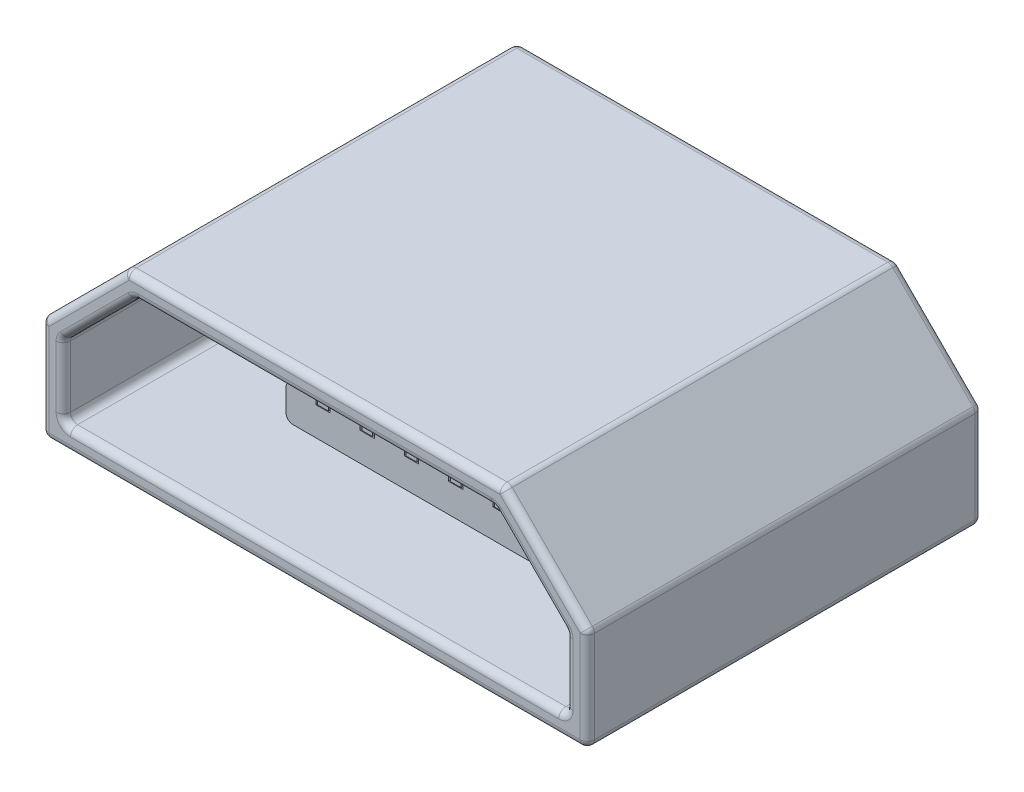
from build123d import *

# Parameters (mm, degrees)
EXTRUDE_THIN1_DEPTH = 5.5
BOSS_EXTRUDE1_DEPTH = 2.5
SKETCH3_W           = 3.5
SKETCH3_H           = 0.5
BOSS_EXTRUDE2_DEPTH = 1.65
SKETCH4_W           = 0.2
SKETCH4_H           = 0.1
CUT_EXTRUDE1_DEPTH  = 1.65
BOSS_EXTRUDE4_REACH = 6.15
SKETCH5_W           = 0.15
SKETCH5_H           = 0.09
FILLET1_R           = 0.1


with BuildPart() as part:
    # Sketch1 → Extrude-Thin1 (new body)
    with BuildSketch(Plane.XY):
        Polygon((-0.3, -0.3), (7.3, -0.3), (7.3, 1.124264069), (6.124264069, 2.3), (0.875735931, 2.3), (-0.3, 1.124264069), align=None)
        Polygon((0, 0), (7, 0), (7, 1), (6, 2), (1, 2), (0, 1), align=None, mode=Mode.SUBTRACT)
    extrude(amount=EXTRUDE_THIN1_DEPTH)

    # Sketch2 → Boss-Extrude1 (add)
    with BuildSketch(Plane(origin=(0, 0, 0), x_dir=(-1, 0, 0), z_dir=(0, 0, -1))):
        Polygon((-6, 2), (-1, 2), (0, 1), (0, 0), (-7, 0), (-7, 1), align=None)
    extrude(amount=-BOSS_EXTRUDE1_DEPTH)

    # Sketch3 → Boss-Extrude2 (add)
    with BuildSketch(Plane.XY.offset(2.5)):
        with Locations((3.5, 0.5)):
            Rectangle(SKETCH3_W, SKETCH3_H)
    extrude(amount=BOSS_EXTRUDE2_DEPTH)

    # Sketch4 → Cut-Extrude1 (cut)
    with BuildSketch(Plane.XY.offset(4.15)):
        with Locations((2.266666667, 0.7)):
            Rectangle(SKETCH4_W, SKETCH4_H)
        with Locations((2.883333333, 0.7)):
            Rectangle(SKETCH4_W, SKETCH4_H)
        with Locations((3.5, 0.7)):
            Rectangle(SKETCH4_W, SKETCH4_H)
        with Locations((4.116666667, 0.7)):
            Rectangle(SKETCH4_W, SKETCH4_H)
        with Locations((4.733333333, 0.7)):
            Rectangle(SKETCH4_W, SKETCH4_H)
    extrude(amount=-CUT_EXTRUDE1_DEPTH, mode=Mode.SUBTRACT)

    # Sketch5 → Boss-Extrude4 (add, up to next)
    with BuildSketch(Plane.XY.offset(4.15), mode=Mode.PRIVATE) as boss_extrude4_sk1:
        with Locations((2.266666667, 0.705)):
            Rectangle(SKETCH5_W, SKETCH5_H)
    boss_extrude4_tool1 = extrude(boss_extrude4_sk1.sketch, amount=-BOSS_EXTRUDE4_REACH, mode=Mode.PRIVATE) - part.part
    add(boss_extrude4_tool1.solids().sort_by_distance((2.266667, 0.705, 4.15))[0])
    # Sketch5 → Boss-Extrude4 (add, up to next)
    with BuildSketch(Plane.XY.offset(4.15), mode=Mode.PRIVATE) as boss_extrude4_sk2:
        with Locations((2.883333333, 0.705)):
            Rectangle(SKETCH5_W, SKETCH5_H)
    boss_extrude4_tool2 = extrude(boss_extrude4_sk2.sketch, amount=-BOSS_EXTRUDE4_REACH, mode=Mode.PRIVATE) - part.part
    add(boss_extrude4_tool2.solids().sort_by_distance((2.883333, 0.705, 4.15))[0])
    # Sketch5 → Boss-Extrude4 (add, up to next)
    with BuildSketch(Plane.XY.offset(4.15), mode=Mode.PRIVATE) as boss_extrude4_sk3:
        with Locations((3.5, 0.705)):
            Rectangle(SKETCH5_W, SKETCH5_H)
    boss_extrude4_tool3 = extrude(boss_extrude4_sk3.sketch, amount=-BOSS_EXTRUDE4_REACH, mode=Mode.PRIVATE) - part.part
    add(boss_extrude4_tool3.solids().sort_by_distance((3.5, 0.705, 4.15))[0])
    # Sketch5 → Boss-Extrude4 (add, up to next)
    with BuildSketch(Plane.XY.offset(4.15), mode=Mode.PRIVATE) as boss_extrude4_sk4:
        with Locations((4.116666667, 0.705)):
            Rectangle(SKETCH5_W, SKETCH5_H)
    boss_extrude4_tool4 = extrude(boss_extrude4_sk4.sketch, amount=-BOSS_EXTRUDE4_REACH, mode=Mode.PRIVATE) - part.part
    add(boss_extrude4_tool4.solids().sort_by_distance((4.116667, 0.705, 4.15))[0])
    # Sketch5 → Boss-Extrude4 (add, up to next)
    with BuildSketch(Plane.XY.offset(4.15), mode=Mode.PRIVATE) as boss_extrude4_sk5:
        with Locations((4.733333333, 0.705)):
            Rectangle(SKETCH5_W, SKETCH5_H)
    boss_extrude4_tool5 = extrude(boss_extrude4_sk5.sketch, amount=-BOSS_EXTRUDE4_REACH, mode=Mode.PRIVATE) - part.part
    add(boss_extrude4_tool5.solids().sort_by_distance((4.733333, 0.705, 4.15))[0])

    # Fillet1
    fillet1_edges = [part.edges().sort_by_distance(p)[0] for p in [
        (7.3, 0.412132034, 5.5),
        (6.712132034, 1.712132034, 5.5),
        (3.5, 2.3, 5.5),
        (0, 1, 4),
        (0.287867966, 1.712132034, 5.5),
        (0, 0, 4),
        (7, 0, 4),
        (7, 1, 4),
        (6, 2, 4),
        (1, 2, 4),
        (0, 0.5, 5.5),
        (3.5, 0, 5.5),
        (7, 0.5, 5.5),
        (6.5, 1.5, 5.5),
        (3.5, 2, 5.5),
        (0.5, 1.5, 5.5),
        (-0.3, 0.412132034, 5.5),
        (0.287867966, 1.712132034, 0),
        (3.5, 2.3, 0),
        (6.712132034, 1.712132034, 0),
        (7.3, 0.412132034, 0),
        (3.5, -0.3, 0),
        (-0.3, 0.412132034, 0),
        (1.75, 0.75, 3.325),
        (1.75, 0.25, 3.325),
        (5.25, 0.25, 3.325),
        (5.25, 0.75, 3.325),
        (3.5, -0.3, 5.5),
        (-0.3, 1.124264069, 2.75),
        (0.875735931, 2.3, 2.75),
        (6.124264069, 2.3, 2.75),
        (7.3, 1.124264069, 2.75),
        (7.3, -0.3, 2.75),
        (-0.3, -0.3, 2.75),
    ]]
    fillet(fillet1_edges, radius=FILLET1_R)


solid = part.part
